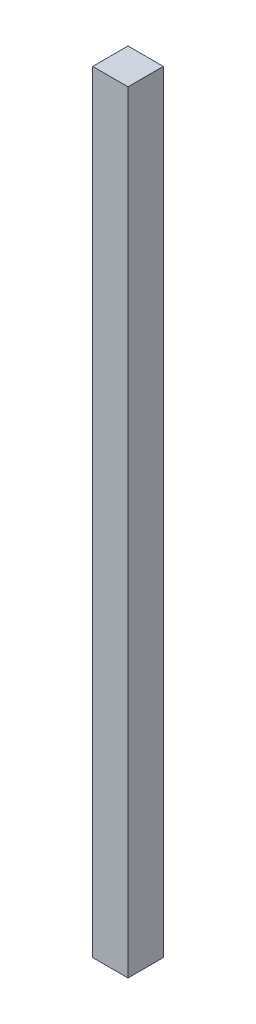
from build123d import *

# Parameters (mm, degrees)
SKETCH1_W           = 25.4
SKETCH1_H           = 25.4
BOSS_EXTRUDE1_DEPTH = 555


with BuildPart() as part:
    # Sketch1 → Boss-Extrude1 (new body)
    with BuildSketch(Plane(origin=(0, 0, 0), x_dir=(1, 0, 0), z_dir=(0, 1, 0))):
        with Locations((-29.269554108, 7.336312554)):
            Rectangle(SKETCH1_W, SKETCH1_H)
    extrude(amount=BOSS_EXTRUDE1_DEPTH)


solid = part.part
